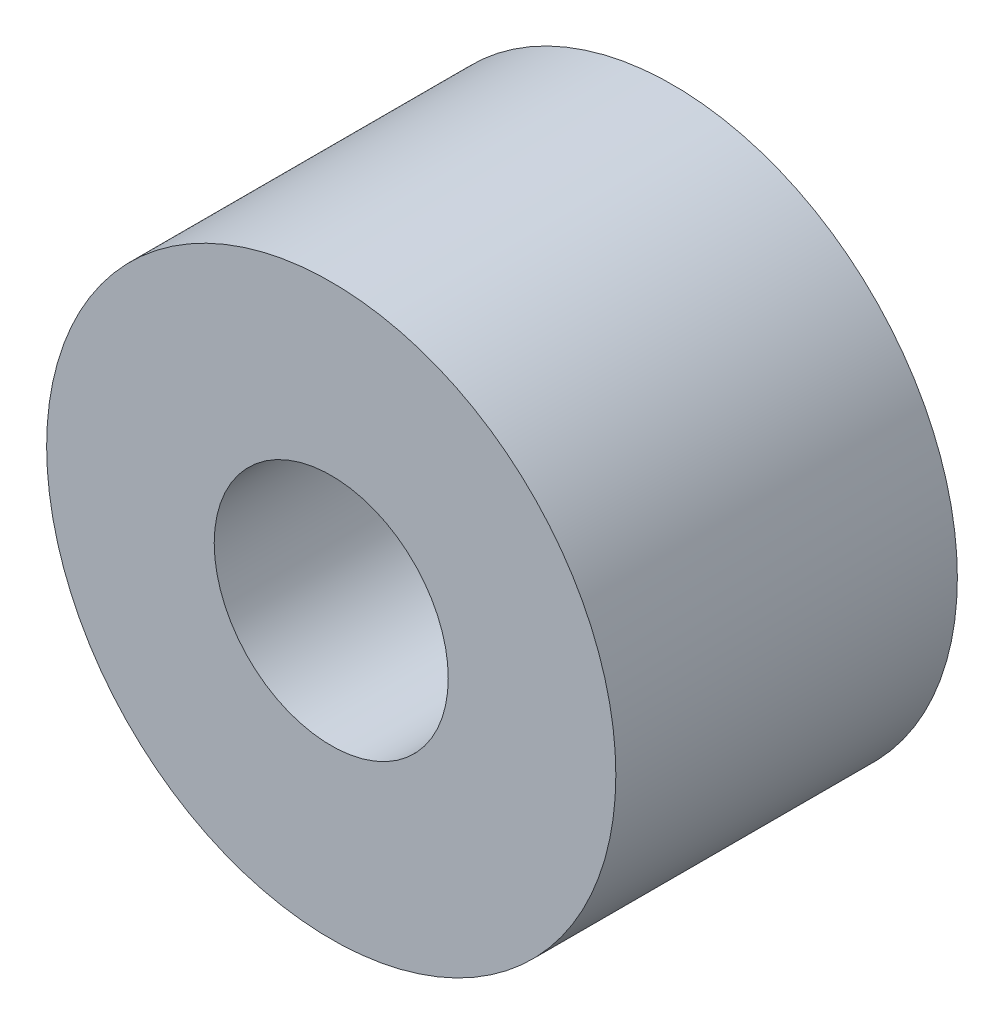
from build123d import *

# Parameters (mm, degrees)
SKETCH1_R               = 7.9375
BOSS_EXTRUDE1_DEPTH     = 9.525
F_1_4_CLEARANCE_HOLE1_D = 6.5278


with BuildPart() as part:
    # Sketch1 → Boss-Extrude1 (new body)
    with BuildSketch(Plane.XY):
        Circle(SKETCH1_R)
    extrude(amount=BOSS_EXTRUDE1_DEPTH)

    # 1/4 Clearance Hole1 (through all)
    with Locations(Plane.XY.offset(9.525)):
        with Locations((0, 0)):
            Hole(F_1_4_CLEARANCE_HOLE1_D / 2)


solid = part.part
